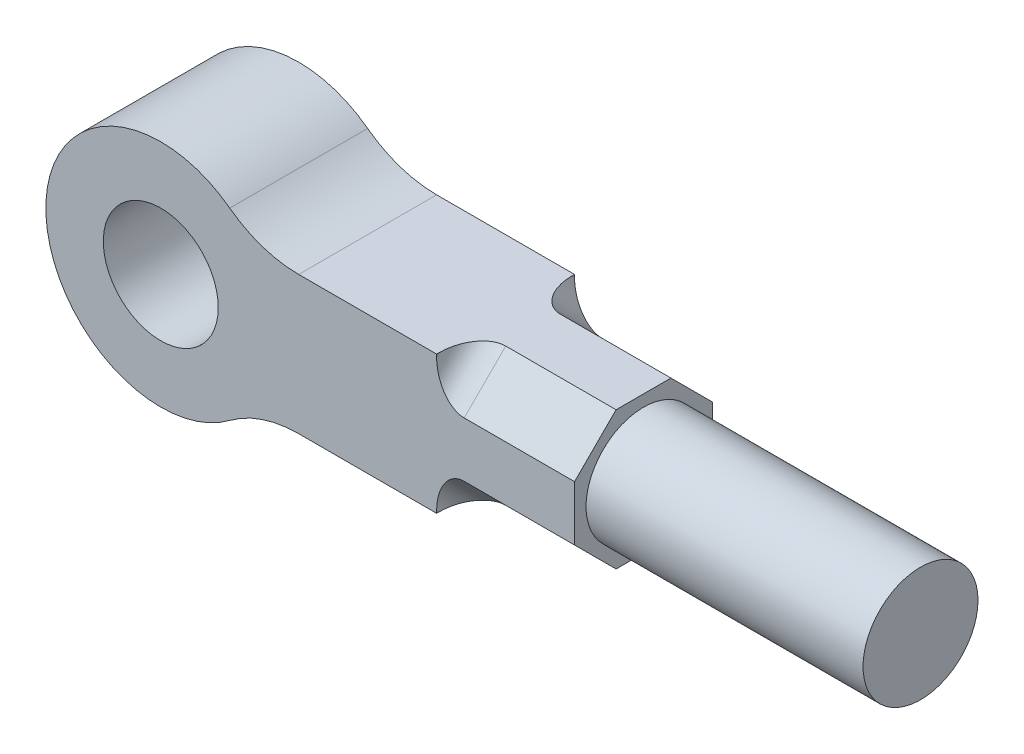
from build123d import *

# Parameters (mm, degrees)
SKETCH1_R           = 250
BOSS_EXTRUDE1_DEPTH = 600
CUT_EXTRUDE1_DEPTH  = 600
SKETCH2_5_R         = 250
BOSS_EXTRUDE2_DEPTH = 1205
FILLET1_R           = 120


with BuildPart() as part:
    # Sketch1 → Boss-Extrude1 (new body)
    with BuildSketch(Plane.XY):
        with BuildLine():
            Line((600, 300), (1800, 300))
            Line((1800, 300), (1800, -300))
            Line((1800, -300), (600, -300))
            ThreePointArc((600, -300), (441.886116992, -325.658350975), (300, -400))
            ThreePointArc((300, -400), (-500, 0), (300, 400))
            ThreePointArc((300, 400), (441.886116992, 325.658350975), (600, 300))
        make_face()
        Circle(SKETCH1_R, mode=Mode.SUBTRACT)
    extrude(amount=BOSS_EXTRUDE1_DEPTH)

    # Sketch2 → Cut-Extrude1 (cut)
    with BuildSketch(Plane(origin=(1800, 0, 0), x_dir=(0, 0, -1), z_dir=(1, 0, 0))):
        Polygon((0, 300), (-180.6, 300), (0, 119.4), align=None)
        Polygon((-600, 119.4), (-419.4, 300), (-600, 300), align=None)
        Polygon((0, -300), (0, -119.4), (-180.6, -300), align=None)
        Polygon((-419.4, -300), (-600, -119.4), (-600, -300), align=None)
    extrude(amount=-CUT_EXTRUDE1_DEPTH, mode=Mode.SUBTRACT)

    # Sketch2_5 → Boss-Extrude2 (add)
    with BuildSketch(Plane(origin=(1800, 0, 0), x_dir=(0, 0, -1), z_dir=(1, 0, 0))):
        with Locations((-300, 0)):
            Circle(SKETCH2_5_R)
    extrude(amount=BOSS_EXTRUDE2_DEPTH)

    # Fillet1
    fillet1_edges = [part.edges().sort_by_distance(p)[0] for p in [
        (1200, -209.7, 90.3),
        (1200, 209.7, 90.3),
        (1200, -209.7, 509.7),
        (1200, 209.7, 509.7),
    ]]
    fillet(fillet1_edges, radius=FILLET1_R)


solid = part.part
